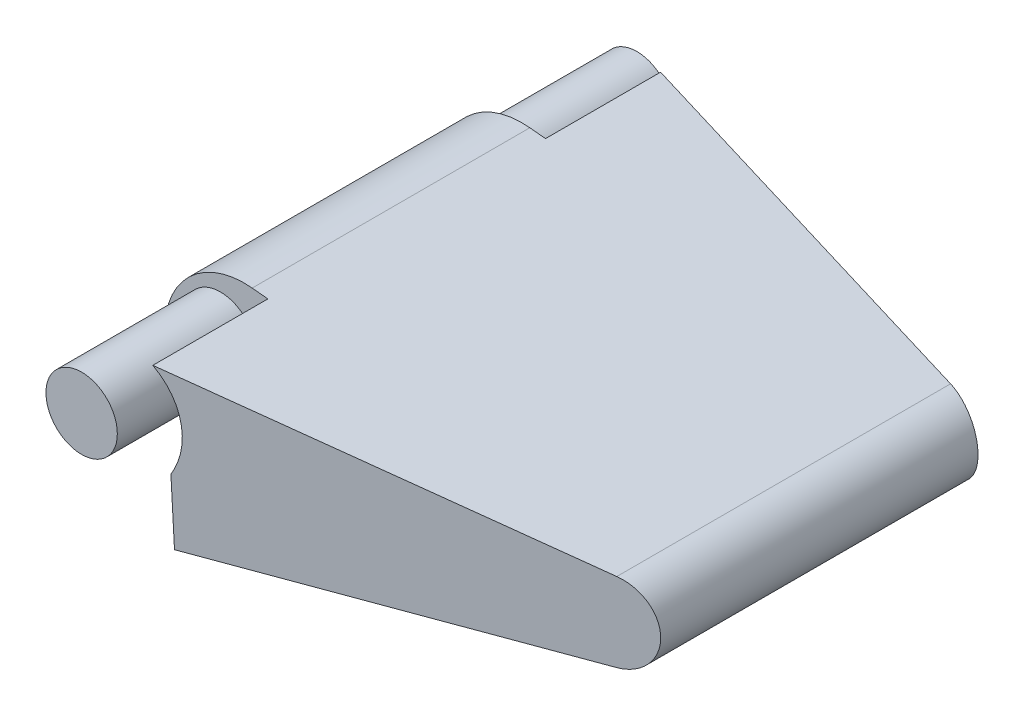
from build123d import *

# Parameters (mm, degrees)
SKETCH2_R               = 2.54
BOSS_EXTRUDE1_DEPTH     = 22.225
CUT_EXTRUDE1_DEPTH      = 7.35
CUT_EXTRUDE1_DEPTH_BACK = 7.35
SKETCH7_R               = 0.9525
CUT_EXTRUDE5_DEPTH      = 0.9525
CUT_EXTRUDE6_DEPTH      = 14.2875
SKETCH11_R              = 2.8575
BOSS_EXTRUDE2_DEPTH     = 22.225
CUT_EXTRUDE7_DEPTH      = 6.35


with BuildPart() as part:
    # Sketch2 → Boss-Extrude1 (new body, symmetric)
    with BuildSketch(Plane.XY):
        with BuildLine():
            Line((0.635, 6.318170226), (32.0675, 3.159085113))
            ThreePointArc((32.0675, 3.159085113), (34.925, 0), (32.0675, -3.159085113))
            Line((32.0675, -3.159085113), (0.635, -6.318170226))
            ThreePointArc((0.635, -6.318170226), (-6.35, 0), (0.635, 6.318170226))
        make_face()
        with Locations((-1.908273726, 1.920652886)):
            Circle(SKETCH2_R, mode=Mode.SUBTRACT)
    extrude(amount=BOSS_EXTRUDE1_DEPTH, both=True)

    # Sketch3 → Cut-Extrude1 (cut, two sides)
    with BuildSketch(Plane(origin=(0, 0, 0), x_dir=(1, 0, 0), z_dir=(0, 1, 0))) as cut_extrude1_sk:
        Polygon((-6.35, 22.225), (34.925, 12.7), (34.925, 31.680918885), align=None)
        Polygon((-6.35, -22.225), (34.925, -12.7), (34.925, -37.636863469), align=None)
    extrude(amount=CUT_EXTRUDE1_DEPTH, mode=Mode.SUBTRACT)
    extrude(cut_extrude1_sk.sketch, amount=-CUT_EXTRUDE1_DEPTH_BACK, mode=Mode.SUBTRACT)

    # Sketch7 → Cut-Extrude5 (cut, symmetric)
    with BuildSketch(Plane.XY):
        with Locations((0, -1.5875)):
            Circle(SKETCH7_R)
    extrude(amount=CUT_EXTRUDE5_DEPTH, both=True, mode=Mode.SUBTRACT)

    # Sketch5 → Cut-Extrude6 (cut)
    with BuildSketch(Plane.XY.offset(25.4)):
        with BuildLine():
            Line((3.064489009, -0.895879696), (3.299937252, -6.050333954))
            Line((3.299937252, -6.050333954), (5.210798469, -13.210091767))
            Line((5.210798469, -13.210091767), (-7.623273726, -5.718328917))
            Line((-7.623273726, -5.718328917), (-7.623273726, 1.920652886))
            ThreePointArc((-7.623273726, 1.920652886), (-0.451927961, 7.446979153), (3.064489009, -0.895879696))
        make_face()
    cut_extrude6 = extrude(amount=-CUT_EXTRUDE6_DEPTH, mode=Mode.SUBTRACT)

    # Mirror2: Cut-Extrude6 across plane
    add(cut_extrude6.mirror(Plane.XY), mode=Mode.SUBTRACT)

    # Sketch11 → Boss-Extrude2 (add, symmetric)
    with BuildSketch(Plane.XY):
        with Locations(Location((-1.908273726, 1.920652886, 0), (0, 0, 180))):  # turned: the seam where the file's is
            Circle(SKETCH11_R)
    extrude(amount=BOSS_EXTRUDE2_DEPTH, both=True)

    # Sketch9 → Cut-Extrude7 (cut)
    with BuildSketch(Plane.XY.offset(0.79375)):
        Polygon((-4.939406342, 3.990584542), (3.064489009, -0.895879696), (3.299937252, -6.050333954), (-14.496579657, -7.838951202), align=None)
    cut_extrude7 = extrude(amount=CUT_EXTRUDE7_DEPTH, mode=Mode.SUBTRACT)

    # Mirror1: Cut-Extrude7 across plane
    add(cut_extrude7.mirror(Plane.XY), mode=Mode.SUBTRACT)


solid = part.part
